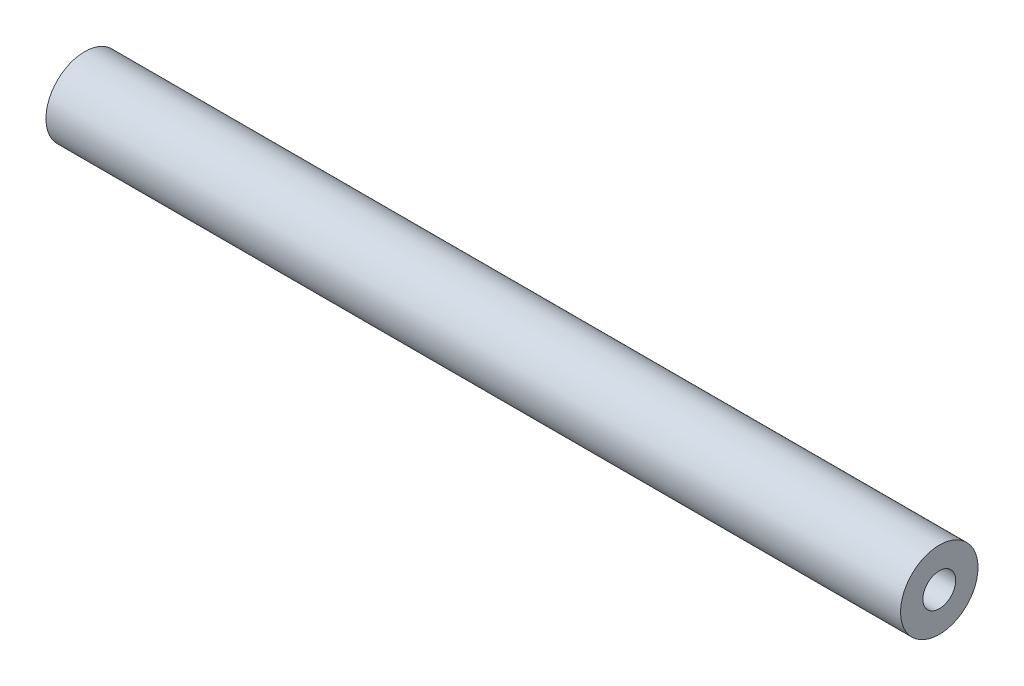
from build123d import *

# Parameters (mm, degrees)
SKETCH1_R              = 4.7625
BOSS_EXTRUDE1_DEPTH    = 105.156
F_10_32_TAPPED_HOLE1_D = 4.0386


with BuildPart() as part:
    # Sketch1 → Boss-Extrude1 (new body)
    with BuildSketch(Plane(origin=(0, 0, 0), x_dir=(0, 0, -1), z_dir=(1, 0, 0))):
        Circle(SKETCH1_R)
    extrude(amount=BOSS_EXTRUDE1_DEPTH)

    # #10-32 Tapped Hole1 (through all)
    with Locations(Plane(origin=(105.156, 0, 0), x_dir=(0, 0, -1), z_dir=(1, 0, 0))):
        with Locations((0, 0)):
            Hole(F_10_32_TAPPED_HOLE1_D / 2)


solid = part.part
